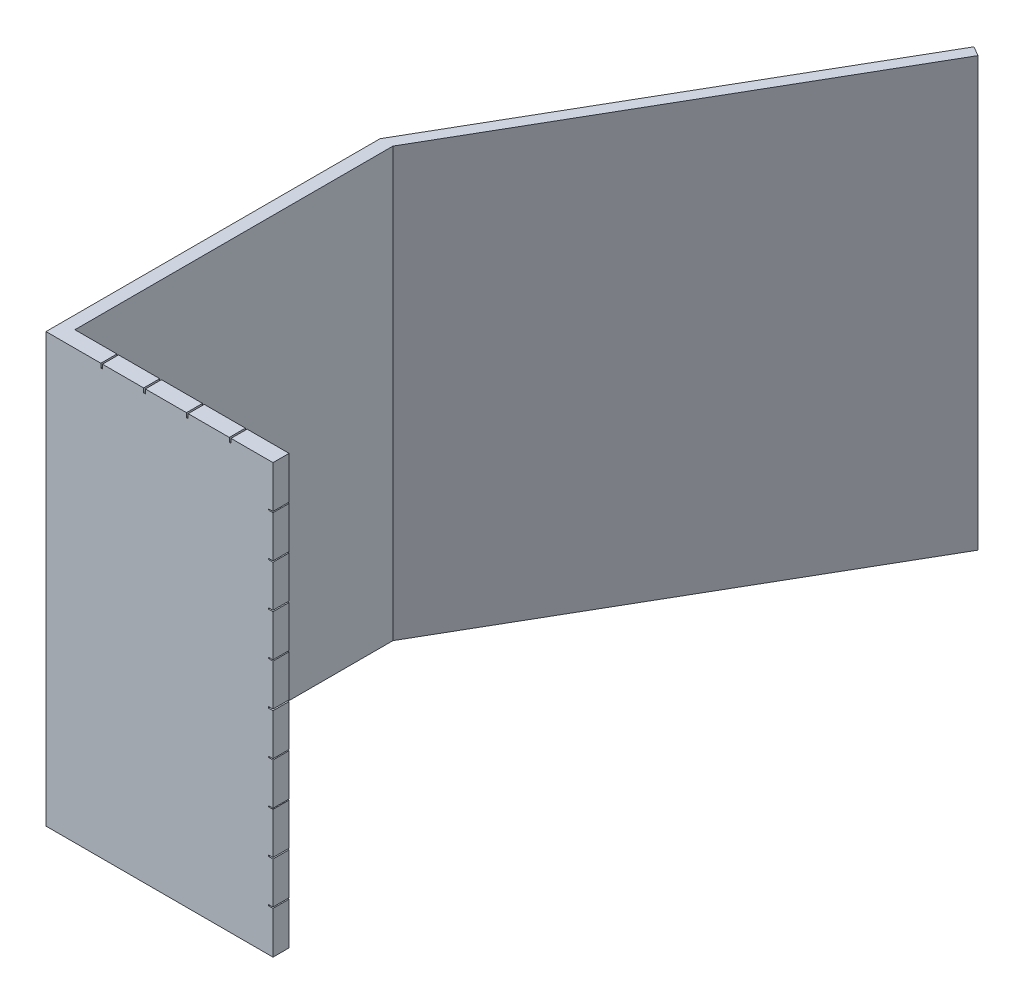
from build123d import *

# Parameters (mm, degrees)
BOSS_EXTRUDE1_DEPTH = 100
SKETCH2_W           = 3.749917695
SKETCH2_H           = 0.25242756
SKETCH2_H_2         = 0.267899142
SKETCH2_H_3         = 0.289005846
SKETCH2_H_4         = 0.253626666
SKETCH2_H_5         = 0.325456574
SKETCH2_H_6         = 0.248885072
SKETCH2_H_7         = 0.22456854
SKETCH2_H_8         = 0.302440332
SKETCH2_H_9         = 0.27412506
CUT_EXTRUDE1_DEPTH  = 1
SKETCH3_W           = 0.401370442
SKETCH3_H           = 3.749917695
SKETCH3_W_2         = 0.402319906
SKETCH3_W_3         = 0.403269369
SKETCH3_W_4         = 0.379270676
CUT_EXTRUDE2_DEPTH  = 1


with BuildPart() as part:
    # Sketch1 → Boss-Extrude1 (new body)
    with BuildSketch(Plane(origin=(0, 0, 0), x_dir=(1, 0, 0), z_dir=(0, 1, 0))):
        Polygon((0.807035346, 30), (50.807035346, 116.602540378), (48.557035346, 117.901578484), (-2.192964654, 30), (-2.192964654, 0), (-2.192964654, -48), (50.807035346, -48), (50.807035346, -44.250082305), (0.807035346, -44.250082305), (0.807035346, -10), (0.807035346, 3.423298646), align=None)
    extrude(amount=BOSS_EXTRUDE1_DEPTH)

    # Sketch2 → Cut-Extrude1 (cut)
    with BuildSketch(Plane(origin=(50.807035346, 0, 0), x_dir=(0, 0, -1), z_dir=(1, 0, 0))):
        with Locations((-46.125041153, 90)):
            Rectangle(SKETCH2_W, SKETCH2_H)
        with Locations((-46.125041153, 80)):
            Rectangle(SKETCH2_W, SKETCH2_H_2)
        with Locations((-46.125041153, 70)):
            Rectangle(SKETCH2_W, SKETCH2_H_3)
        with Locations((-46.125041153, 60)):
            Rectangle(SKETCH2_W, SKETCH2_H_4)
        with Locations((-46.125041153, 50)):
            Rectangle(SKETCH2_W, SKETCH2_H_5)
        with Locations((-46.125041153, 40)):
            Rectangle(SKETCH2_W, SKETCH2_H_6)
        with Locations((-46.125041153, 30)):
            Rectangle(SKETCH2_W, SKETCH2_H_7)
        with Locations((-46.125041153, 20)):
            Rectangle(SKETCH2_W, SKETCH2_H_8)
        with Locations((-46.125041153, 10)):
            Rectangle(SKETCH2_W, SKETCH2_H_9)
    extrude(amount=-CUT_EXTRUDE1_DEPTH, mode=Mode.SUBTRACT)

    # Sketch3 → Cut-Extrude2 (cut)
    with BuildSketch(Plane(origin=(0, 100, 0), x_dir=(1, 0, 0), z_dir=(0, 1, 0))):
        with Locations((40.807035346, -46.125041153)):
            Rectangle(SKETCH3_W, SKETCH3_H)
        with Locations((30.807035346, -46.125041153)):
            Rectangle(SKETCH3_W_2, SKETCH3_H)
        with Locations((20.807035346, -46.125041153)):
            Rectangle(SKETCH3_W_3, SKETCH3_H)
        with Locations((10.807035346, -46.125041153)):
            Rectangle(SKETCH3_W_4, SKETCH3_H)
    extrude(amount=-CUT_EXTRUDE2_DEPTH, mode=Mode.SUBTRACT)


solid = part.part
